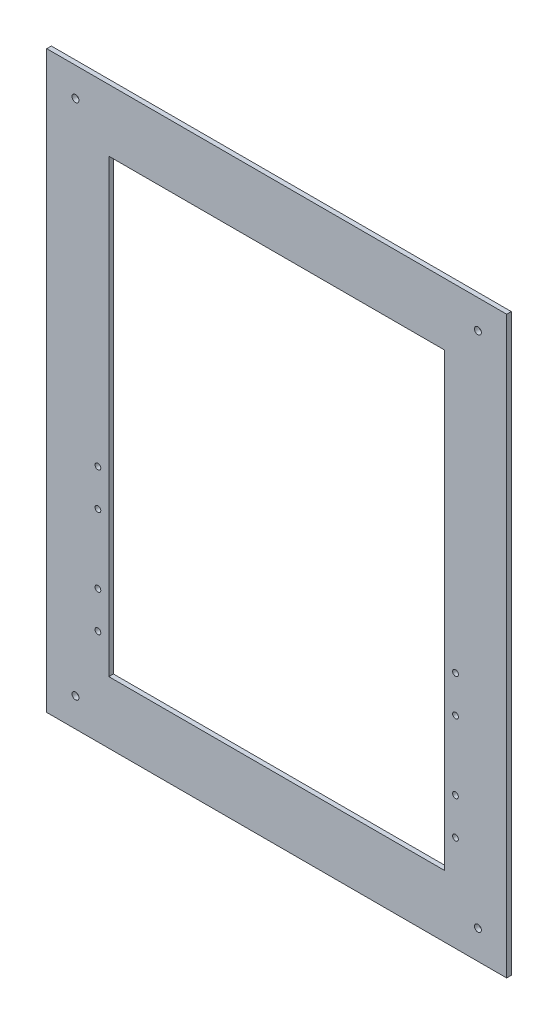
from build123d import *

# Parameters (mm, degrees)
SKETCH1_W           = 400
SKETCH1_H           = 500
BOSS_EXTRUDE1_DEPTH = 4
CUT_EXTRUDE1_REACH  = 6
SKETCH3_W           = 292
SKETCH3_H           = 392
SKETCH6_R           = 2.5
CUT_EXTRUDE3_DEPTH  = 4
SKETCH7_R           = 3
CUT_EXTRUDE4_DEPTH  = 4


with BuildPart() as part:
    # Sketch1 → Boss-Extrude1 (new body)
    with BuildSketch(Plane.XY):
        with Locations((200, 250)):
            Rectangle(SKETCH1_W, SKETCH1_H)
    extrude(amount=BOSS_EXTRUDE1_DEPTH)

    # Sketch3 → Cut-Extrude1 (cut, up to next)
    with BuildSketch(Plane.XY.offset(4), mode=Mode.PRIVATE) as cut_extrude1_sk1:
        with Locations((200, 250)):
            Rectangle(SKETCH3_W, SKETCH3_H)
    cut_extrude1_tool1 = extrude(cut_extrude1_sk1.sketch, amount=-CUT_EXTRUDE1_REACH, mode=Mode.PRIVATE) & part.part
    add(cut_extrude1_tool1.solids().sort_by_distance((200, 250, 4))[0], mode=Mode.SUBTRACT)

    # Sketch6 → Cut-Extrude3 (cut)
    with BuildSketch(Plane.XY.offset(4)):
        with Locations((355.5, 83.5)):
            Circle(SKETCH6_R)
        with Locations((355.5, 115.5)):
            Circle(SKETCH6_R)
        with Locations((355.5, 175.5)):
            Circle(SKETCH6_R)
        with Locations((355.5, 207.5)):
            Circle(SKETCH6_R)
    cut_extrude3 = extrude(amount=-CUT_EXTRUDE3_DEPTH, mode=Mode.SUBTRACT)

    # Mirror1: Cut-Extrude3 across plane
    add(cut_extrude3.mirror(Plane(origin=(200, 0, 0), x_dir=(0, 0, 1), z_dir=(1, 0, 0))), mode=Mode.SUBTRACT)

    # Sketch7 → Cut-Extrude4 (cut)
    with BuildSketch(Plane.XY.offset(4)):
        with Locations((375, 475)):
            Circle(SKETCH7_R)
        with Locations((25, 475)):
            Circle(SKETCH7_R)
        with Locations((25, 25)):
            Circle(SKETCH7_R)
        with Locations((375, 25)):
            Circle(SKETCH7_R)
    extrude(amount=-CUT_EXTRUDE4_DEPTH, mode=Mode.SUBTRACT)


solid = part.part
